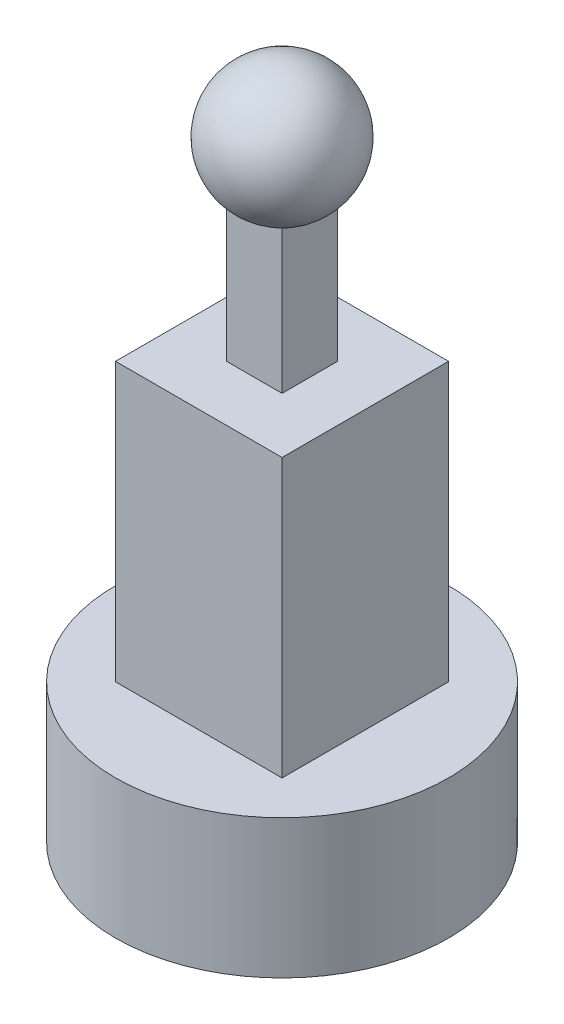
from build123d import *

# Parameters (mm, degrees)
SKETCH1_R           = 30
BOSS_EXTRUDE1_DEPTH = 25
BOSS_EXTRUDE2_DEPTH = 50
SKETCH4_W           = 10
SKETCH4_H           = 10
BOSS_EXTRUDE3_DEPTH = 30


with BuildPart() as part:
    # Sketch1 → Boss-Extrude1 (new body)
    with BuildSketch(Plane(origin=(0, 0, 0), x_dir=(1, 0, 0), z_dir=(0, 1, 0))):
        Circle(SKETCH1_R)
    extrude(amount=BOSS_EXTRUDE1_DEPTH)

    # Sketch3 → Boss-Extrude2 (add)
    with BuildSketch(Plane(origin=(0, 25, 0), x_dir=(1, 0, 0), z_dir=(0, 1, 0))):
        Polygon((-15, 0.769018566), (-15, 15), (15, 15), (15, -15), (-15, -15), align=None)
    extrude(amount=BOSS_EXTRUDE2_DEPTH)

    # Sketch4 → Boss-Extrude3 (add)
    with BuildSketch(Plane(origin=(0, 75, 0), x_dir=(1, 0, 0), z_dir=(0, 1, 0))):
        Rectangle(SKETCH4_W, SKETCH4_H)
    extrude(amount=BOSS_EXTRUDE3_DEPTH)

    # Sketch7 → Revolve1 (revolve)
    with BuildSketch(Plane(origin=(0, 110, 0), x_dir=(1, 0, 0), z_dir=(0, 1, 0))):
        with BuildLine():
            Line((0, 11.606043258), (0, -11.606043258))
            ThreePointArc((0, -11.606043258), (11.606043258, 0), (0, 11.606043258))
        make_face()
    revolve(axis=Axis((0, 110, -11.606043258), (0, 0, 1)))


solid = part.part
